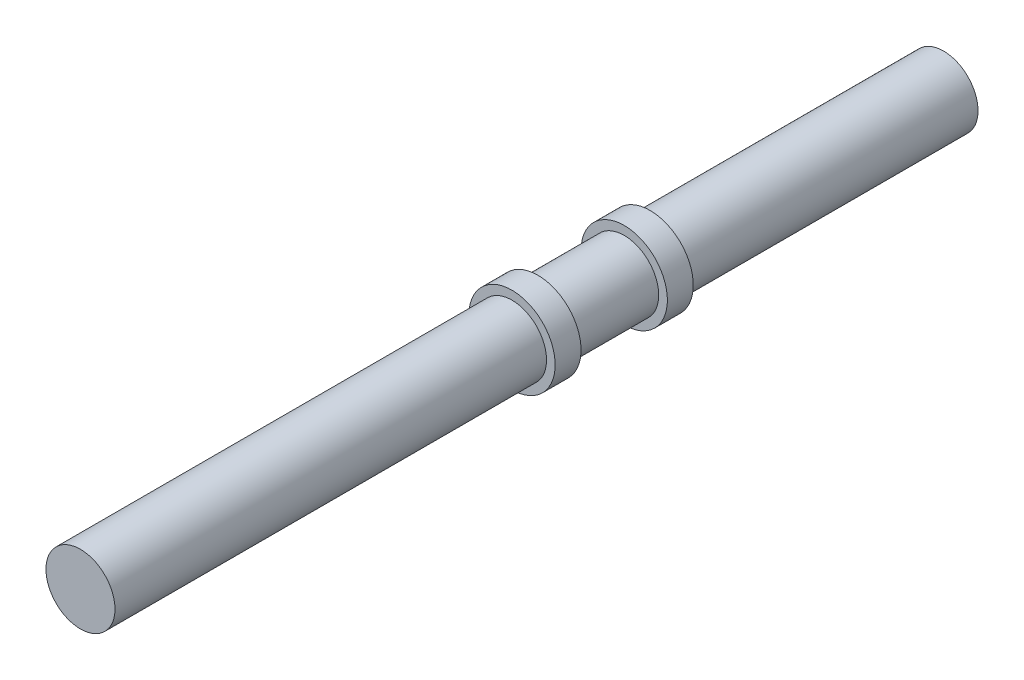
from build123d import *

# Parameters (mm, degrees)
SKETCH1_R           = 4
BOSS_EXTRUDE1_DEPTH = 50
SKETCH2_R           = 5
BOSS_EXTRUDE2_DEPTH = 3
SKETCH3_R           = 4
BOSS_EXTRUDE3_DEPTH = 10
SKETCH4_R           = 5
BOSS_EXTRUDE4_DEPTH = 3
SKETCH5_R           = 4
BOSS_EXTRUDE5_DEPTH = 34


with BuildPart() as part:
    # Sketch1 → Boss-Extrude1 (new body)
    with BuildSketch(Plane.XY):
        Circle(SKETCH1_R)
    extrude(amount=BOSS_EXTRUDE1_DEPTH)

    # Sketch2 → Boss-Extrude2 (add)
    with BuildSketch(Plane(origin=(0, 0, 0), x_dir=(-1, 0, 0), z_dir=(0, 0, -1))):
        Circle(SKETCH2_R)
    extrude(amount=BOSS_EXTRUDE2_DEPTH)

    # Sketch3 → Boss-Extrude3 (add)
    with BuildSketch(Plane(origin=(0, 0, -3), x_dir=(-1, 0, 0), z_dir=(0, 0, -1))):
        Circle(SKETCH3_R)
    extrude(amount=BOSS_EXTRUDE3_DEPTH)

    # Sketch4 → Boss-Extrude4 (add)
    with BuildSketch(Plane(origin=(0, 0, -13), x_dir=(-1, 0, 0), z_dir=(0, 0, -1))):
        Circle(SKETCH4_R)
    extrude(amount=BOSS_EXTRUDE4_DEPTH)

    # Sketch5 → Boss-Extrude5 (add)
    with BuildSketch(Plane(origin=(0, 0, -16), x_dir=(-1, 0, 0), z_dir=(0, 0, -1))):
        Circle(SKETCH5_R)
    extrude(amount=BOSS_EXTRUDE5_DEPTH)


solid = part.part
